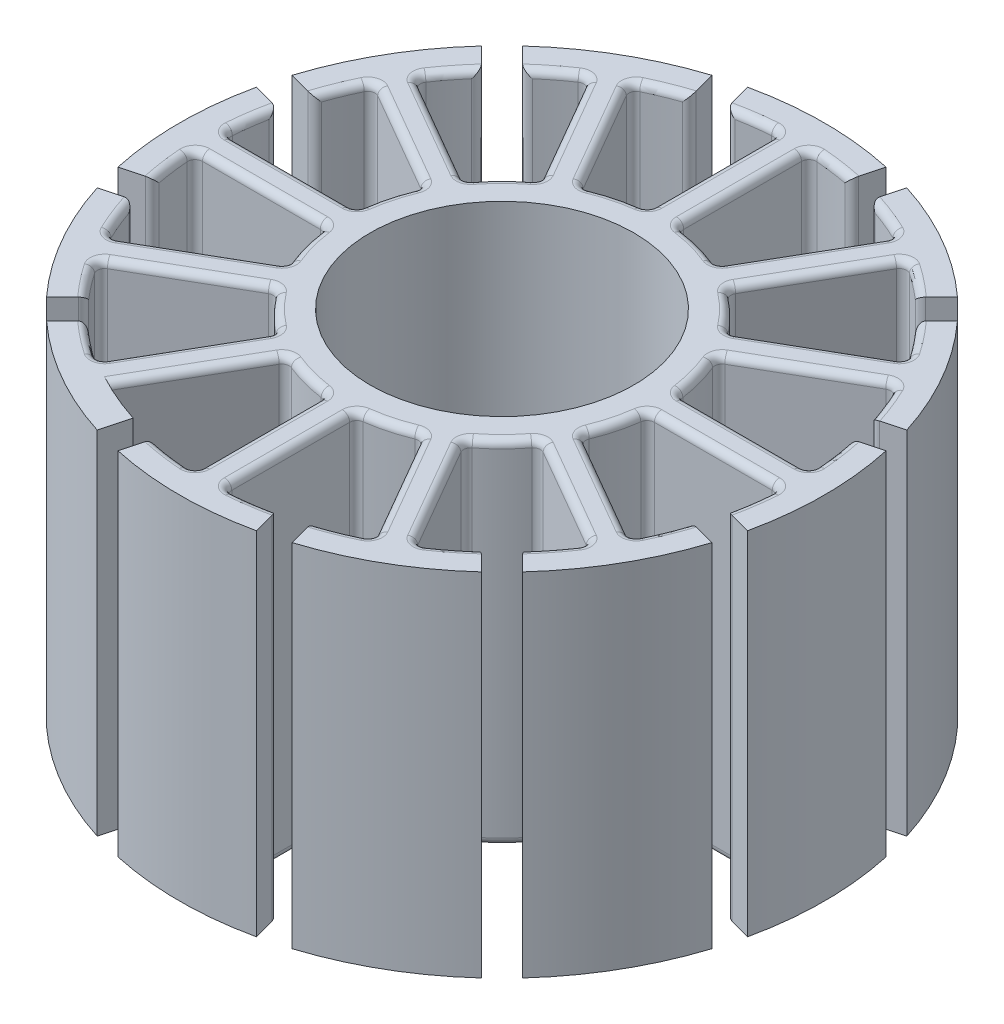
from build123d import *

# Parameters (mm, degrees)
SKETCH1_R           = 5.5
SKETCH1_R_2         = 4.5
BOSS_EXTRUDE1_DEPTH = 12
FILLET2_R           = 0.25


with BuildPart() as part:
    # Sketch1 → Boss-Extrude1 (new body)
    with BuildSketch(Plane(origin=(0, 0, 0), x_dir=(1, 0, 0), z_dir=(0, 1, 0))):
        Circle(SKETCH1_R)
        Circle(SKETCH1_R_2, mode=Mode.SUBTRACT)
        with BuildLine():
            ThreePointArc((-4.49341649, -3.171625489), (-4.763139721, -2.75), (-4.99341649, -2.305600086))
            Line((-4.99341649, -2.305600086), (-8.899421946, -4.560733387))
            ThreePointArc((-8.899421946, -4.560733387), (-8.660254038, -5), (-8.399421946, -5.426758791))
            Line((-8.399421946, -5.426758791), (-4.49341649, -3.171625489))
        make_face()
        with BuildLine():
            ThreePointArc((-5.477225575, -0.5), (-5.5, 0), (-5.477225575, 0.5))
            Line((-5.477225575, 0.5), (-9.987492178, 0.5))
            ThreePointArc((-9.987492178, 0.5), (-10, 0), (-9.987492178, -0.5))
            Line((-9.987492178, -0.5), (-5.477225575, -0.5))
        make_face()
        with BuildLine():
            ThreePointArc((-4.99341649, 2.305600086), (-4.763139721, 2.75), (-4.49341649, 3.171625489))
            Line((-4.49341649, 3.171625489), (-8.399421946, 5.426758791))
            ThreePointArc((-8.399421946, 5.426758791), (-8.660254038, 5), (-8.899421946, 4.560733387))
            Line((-8.899421946, 4.560733387), (-4.99341649, 2.305600086))
        make_face()
        with BuildLine():
            ThreePointArc((-3.171625489, 4.49341649), (-2.75, 4.763139721), (-2.305600086, 4.99341649))
            Line((-2.305600086, 4.99341649), (-4.560733387, 8.899421946))
            ThreePointArc((-4.560733387, 8.899421946), (-5, 8.660254038), (-5.426758791, 8.399421946))
            Line((-5.426758791, 8.399421946), (-3.171625489, 4.49341649))
        make_face()
        with BuildLine():
            ThreePointArc((0.5, 9.987492178), (0, 10), (-0.5, 9.987492178))
            Line((-0.5, 9.987492178), (-0.5, 5.477225575))
            ThreePointArc((-0.5, 5.477225575), (0, 5.5), (0.5, 5.477225575))
            Line((0.5, 5.477225575), (0.5, 9.987492178))
        make_face()
        with BuildLine():
            Line((4.560733387, 8.899421946), (2.305600086, 4.99341649))
            ThreePointArc((2.305600086, 4.99341649), (2.75, 4.763139721), (3.171625489, 4.49341649))
            Line((3.171625489, 4.49341649), (5.426758791, 8.399421946))
            ThreePointArc((5.426758791, 8.399421946), (5, 8.660254038), (4.560733387, 8.899421946))
        make_face()
        with BuildLine():
            Line((8.399421946, 5.426758791), (4.49341649, 3.171625489))
            ThreePointArc((4.49341649, 3.171625489), (4.763139721, 2.75), (4.99341649, 2.305600086))
            Line((4.99341649, 2.305600086), (8.899421946, 4.560733387))
            ThreePointArc((8.899421946, 4.560733387), (8.660254038, 5), (8.399421946, 5.426758791))
        make_face()
        with BuildLine():
            Line((9.987492178, 0.5), (5.477225575, 0.5))
            ThreePointArc((5.477225575, 0.5), (5.494303444, 0.250259203), (5.5, 0))
            ThreePointArc((5.5, 0), (5.494303444, -0.250259203), (5.477225575, -0.5))
            Line((5.477225575, -0.5), (9.987492178, -0.5))
            ThreePointArc((9.987492178, -0.5), (9.996872555, -0.250078211), (10, 0))
            ThreePointArc((10, 0), (9.996872555, 0.250078211), (9.987492178, 0.5))
        make_face()
        with BuildLine():
            Line((8.899421946, -4.560733387), (4.99341649, -2.305600086))
            ThreePointArc((4.99341649, -2.305600086), (4.763139721, -2.75), (4.49341649, -3.171625489))
            Line((4.49341649, -3.171625489), (8.399421946, -5.426758791))
            ThreePointArc((8.399421946, -5.426758791), (8.660254038, -5), (8.899421946, -4.560733387))
        make_face()
        with BuildLine():
            Line((5.426758791, -8.399421946), (3.171625489, -4.49341649))
            ThreePointArc((3.171625489, -4.49341649), (2.75, -4.763139721), (2.305600086, -4.99341649))
            Line((2.305600086, -4.99341649), (4.560733387, -8.899421946))
            ThreePointArc((4.560733387, -8.899421946), (5, -8.660254038), (5.426758791, -8.399421946))
        make_face()
        with BuildLine():
            ThreePointArc((0.5, -5.477225575), (0, -5.5), (-0.5, -5.477225575))
            Line((-0.5, -5.477225575), (-0.5, -9.987492178))
            ThreePointArc((-0.5, -9.987492178), (0, -10), (0.5, -9.987492178))
            Line((0.5, -9.987492178), (0.5, -5.477225575))
        make_face()
        with BuildLine():
            ThreePointArc((-2.305600086, -4.99341649), (-2.75, -4.763139721), (-3.171625489, -4.49341649))
            Line((-3.171625489, -4.49341649), (-5.426758791, -8.399421946))
            ThreePointArc((-5.426758791, -8.399421946), (-5, -8.660254038), (-4.560733387, -8.899421946))
            Line((-4.560733387, -8.899421946), (-2.305600086, -4.99341649))
        make_face()
        with BuildLine():
            ThreePointArc((-4.560733387, -8.899421946), (-5, -8.660254038), (-5.426758791, -8.399421946))
            ThreePointArc((-5.426758791, -8.399421946), (-6.08761429, -7.933533403), (-6.708670055, -7.415776837))
            Line((-6.708670055, -7.415776837), (-7.416581743, -8.123688525))
            ThreePointArc((-7.416581743, -8.123688525), (-5.5, -9.526279442), (-3.327029763, -10.484792461))
            Line((-3.327029763, -10.484792461), (-3.067916102, -9.517767112))
            ThreePointArc((-3.067916102, -9.517767112), (-3.826834324, -9.238795325), (-4.560733387, -8.899421946))
        make_face()
        with BuildLine():
            ThreePointArc((-8.399421946, -5.426758791), (-8.660254038, -5), (-8.899421946, -4.560733387))
            ThreePointArc((-8.899421946, -4.560733387), (-9.238795325, -3.826834324), (-9.517767112, -3.067916102))
            Line((-9.517767112, -3.067916102), (-10.484792461, -3.327029763))
            ThreePointArc((-10.484792461, -3.327029763), (-9.526279442, -5.5), (-8.123688525, -7.416581743))
            Line((-8.123688525, -7.416581743), (-7.415776837, -6.708670055))
            ThreePointArc((-7.415776837, -6.708670055), (-7.933533403, -6.08761429), (-8.399421946, -5.426758791))
        make_face()
        with BuildLine():
            ThreePointArc((-9.987492178, -0.5), (-10, 0), (-9.987492178, 0.5))
            ThreePointArc((-9.987492178, 0.5), (-9.914448614, 1.305261922), (-9.776586157, 2.101990275))
            Line((-9.776586157, 2.101990275), (-10.743611506, 2.361103937))
            ThreePointArc((-10.743611506, 2.361103937), (-11, 0), (-10.743611506, -2.361103937))
            Line((-10.743611506, -2.361103937), (-9.776586157, -2.101990275))
            ThreePointArc((-9.776586157, -2.101990275), (-9.914448614, -1.305261922), (-9.987492178, -0.5))
        make_face()
        with BuildLine():
            ThreePointArc((-4.560733387, 8.899421946), (-3.826834324, 9.238795325), (-3.067916102, 9.517767112))
            Line((-3.067916102, 9.517767112), (-3.327029763, 10.484792461))
            ThreePointArc((-3.327029763, 10.484792461), (-5.5, 9.526279442), (-7.416581743, 8.123688525))
            Line((-7.416581743, 8.123688525), (-6.708670055, 7.415776837))
            ThreePointArc((-6.708670055, 7.415776837), (-6.08761429, 7.933533403), (-5.426758791, 8.399421946))
            ThreePointArc((-5.426758791, 8.399421946), (-5, 8.660254038), (-4.560733387, 8.899421946))
        make_face()
        with BuildLine():
            ThreePointArc((-8.899421946, 4.560733387), (-8.660254038, 5), (-8.399421946, 5.426758791))
            ThreePointArc((-8.399421946, 5.426758791), (-7.933533403, 6.08761429), (-7.415776837, 6.708670055))
            Line((-7.415776837, 6.708670055), (-8.123688525, 7.416581743))
            ThreePointArc((-8.123688525, 7.416581743), (-9.526279442, 5.5), (-10.484792461, 3.327029763))
            Line((-10.484792461, 3.327029763), (-9.517767112, 3.067916102))
            ThreePointArc((-9.517767112, 3.067916102), (-9.238795325, 3.826834324), (-8.899421946, 4.560733387))
        make_face()
        with BuildLine():
            ThreePointArc((-2.101990275, 9.776586157), (-1.305261922, 9.914448614), (-0.5, 9.987492178))
            ThreePointArc((-0.5, 9.987492178), (0, 10), (0.5, 9.987492178))
            ThreePointArc((0.5, 9.987492178), (1.305261922, 9.914448614), (2.101990275, 9.776586157))
            Line((2.101990275, 9.776586157), (2.361103937, 10.743611506))
            ThreePointArc((2.361103937, 10.743611506), (0, 11), (-2.361103937, 10.743611506))
            Line((-2.361103937, 10.743611506), (-2.101990275, 9.776586157))
        make_face()
        with BuildLine():
            Line((3.327029763, 10.484792461), (3.067916102, 9.517767112))
            ThreePointArc((3.067916102, 9.517767112), (3.826834324, 9.238795325), (4.560733387, 8.899421946))
            ThreePointArc((4.560733387, 8.899421946), (5, 8.660254038), (5.426758791, 8.399421946))
            ThreePointArc((5.426758791, 8.399421946), (6.08761429, 7.933533403), (6.708670055, 7.415776837))
            Line((6.708670055, 7.415776837), (7.416581743, 8.123688525))
            ThreePointArc((7.416581743, 8.123688525), (5.5, 9.526279442), (3.327029763, 10.484792461))
        make_face()
        with BuildLine():
            ThreePointArc((7.415776837, 6.708670055), (7.933533403, 6.08761429), (8.399421946, 5.426758791))
            ThreePointArc((8.399421946, 5.426758791), (8.660254038, 5), (8.899421946, 4.560733387))
            ThreePointArc((8.899421946, 4.560733387), (9.238795325, 3.826834324), (9.517767112, 3.067916102))
            Line((9.517767112, 3.067916102), (10.484792461, 3.327029763))
            ThreePointArc((10.484792461, 3.327029763), (9.526279442, 5.5), (8.123688525, 7.416581743))
            Line((8.123688525, 7.416581743), (7.415776837, 6.708670055))
        make_face()
        with BuildLine():
            ThreePointArc((9.776586157, 2.101990275), (9.914448614, 1.305261922), (9.987492178, 0.5))
            ThreePointArc((9.987492178, 0.5), (9.996872555, 0.250078211), (10, 0))
            ThreePointArc((10, 0), (9.996872555, -0.250078211), (9.987492178, -0.5))
            ThreePointArc((9.987492178, -0.5), (9.914448614, -1.305261922), (9.776586157, -2.101990275))
            Line((9.776586157, -2.101990275), (10.743611506, -2.361103937))
            ThreePointArc((10.743611506, -2.361103937), (10.935715033, -1.187491775), (11, 0))
            ThreePointArc((11, 0), (10.935715033, 1.187491775), (10.743611506, 2.361103937))
            Line((10.743611506, 2.361103937), (9.776586157, 2.101990275))
        make_face()
        with BuildLine():
            ThreePointArc((9.517767112, -3.067916102), (9.238795325, -3.826834324), (8.899421946, -4.560733387))
            ThreePointArc((8.899421946, -4.560733387), (8.660254038, -5), (8.399421946, -5.426758791))
            ThreePointArc((8.399421946, -5.426758791), (7.933533403, -6.08761429), (7.415776837, -6.708670055))
            Line((7.415776837, -6.708670055), (8.123688525, -7.416581743))
            ThreePointArc((8.123688525, -7.416581743), (9.526279442, -5.5), (10.484792461, -3.327029763))
            Line((10.484792461, -3.327029763), (9.517767112, -3.067916102))
        make_face()
        with BuildLine():
            ThreePointArc((6.708670055, -7.415776837), (6.08761429, -7.933533403), (5.426758791, -8.399421946))
            ThreePointArc((5.426758791, -8.399421946), (5, -8.660254038), (4.560733387, -8.899421946))
            ThreePointArc((4.560733387, -8.899421946), (3.826834324, -9.238795325), (3.067916102, -9.517767112))
            Line((3.067916102, -9.517767112), (3.327029763, -10.484792461))
            ThreePointArc((3.327029763, -10.484792461), (5.5, -9.526279442), (7.416581743, -8.123688525))
            Line((7.416581743, -8.123688525), (6.708670055, -7.415776837))
        make_face()
        with BuildLine():
            ThreePointArc((0.5, -9.987492178), (0, -10), (-0.5, -9.987492178))
            ThreePointArc((-0.5, -9.987492178), (-1.305261922, -9.914448614), (-2.101990275, -9.776586157))
            Line((-2.101990275, -9.776586157), (-2.361103937, -10.743611506))
            ThreePointArc((-2.361103937, -10.743611506), (0, -11), (2.361103937, -10.743611506))
            Line((2.361103937, -10.743611506), (2.101990275, -9.776586157))
            ThreePointArc((2.101990275, -9.776586157), (1.305261922, -9.914448614), (0.5, -9.987492178))
        make_face()
    extrude(amount=BOSS_EXTRUDE1_DEPTH)

    # Fillet2
    fillet2_edges = [part.edges().sort_by_distance(p)[0] for p in [
        (0.5, 0, 7.732358876),
        (0.5, 12, 7.732358876),
        (3.433166736, 0, 6.946419218),
        (3.433166736, 12, 6.946419218),
        (-3.433166736, 0, 6.946419218),
        (-3.433166736, 12, 6.946419218),
        (-0.5, 0, 7.732358876),
        (-0.5, 12, 7.732358876),
        (-6.446419218, 0, 4.29919214),
        (-6.446419218, 12, 4.29919214),
        (-4.29919214, 0, 6.446419218),
        (-4.29919214, 12, 6.446419218),
        (-7.732358876, 0, 0.5),
        (-7.732358876, 12, 0.5),
        (-6.946419218, 0, 3.433166736),
        (-6.946419218, 12, 3.433166736),
        (-6.946419218, 0, -3.433166736),
        (-6.946419218, 12, -3.433166736),
        (-7.732358876, 0, -0.5),
        (-7.732358876, 12, -0.5),
        (-4.29919214, 0, -6.446419218),
        (-4.29919214, 12, -6.446419218),
        (-6.446419218, 0, -4.29919214),
        (-6.446419218, 12, -4.29919214),
        (-0.5, 0, -7.732358876),
        (-0.5, 12, -7.732358876),
        (-3.433166736, 0, -6.946419218),
        (-3.433166736, 12, -6.946419218),
        (3.433166736, 0, -6.946419218),
        (3.433166736, 12, -6.946419218),
        (0.5, 0, -7.732358876),
        (0.5, 12, -7.732358876),
        (6.446419218, 0, -4.29919214),
        (6.446419218, 12, -4.29919214),
        (4.29919214, 0, -6.446419218),
        (4.29919214, 12, -6.446419218),
        (7.732358876, 0, -0.5),
        (7.732358876, 12, -0.5),
        (6.946419218, 0, -3.433166736),
        (6.946419218, 12, -3.433166736),
        (6.946419218, 0, 3.433166736),
        (6.946419218, 12, 3.433166736),
        (7.732358876, 0, 0.5),
        (7.732358876, 12, 0.5),
        (4.29919214, 0, 6.446419218),
        (4.29919214, 12, 6.446419218),
        (6.446419218, 0, 4.29919214),
        (6.446419218, 12, 4.29919214),
        (0.5, 6, 5.477225575),
        (1.423504748, 12, 5.312592045),
        (1.423504748, 0, 5.312592045),
        (2.305600086, 6, 4.99341649),
        (-2.305600086, 6, 4.99341649),
        (-1.423504748, 12, 5.312592045),
        (-1.423504748, 0, 5.312592045),
        (-0.5, 6, 5.477225575),
        (-4.49341649, 6, 3.171625489),
        (-3.889087297, 12, 3.889087297),
        (-3.889087297, 0, 3.889087297),
        (-3.171625489, 6, 4.49341649),
        (-5.477225575, 6, 0.5),
        (-5.312592045, 12, 1.423504748),
        (-5.312592045, 0, 1.423504748),
        (-4.99341649, 6, 2.305600086),
        (-4.99341649, 6, -2.305600086),
        (-5.312592045, 12, -1.423504748),
        (-5.312592045, 0, -1.423504748),
        (-5.477225575, 6, -0.5),
        (-3.171625489, 6, -4.49341649),
        (-3.889087297, 12, -3.889087297),
        (-3.889087297, 0, -3.889087297),
        (-4.49341649, 6, -3.171625489),
        (-0.5, 6, -5.477225575),
        (-1.423504748, 12, -5.312592045),
        (-1.423504748, 0, -5.312592045),
        (-2.305600086, 6, -4.99341649),
        (2.305600086, 6, -4.99341649),
        (1.423504748, 12, -5.312592045),
        (1.423504748, 0, -5.312592045),
        (0.5, 6, -5.477225575),
        (4.49341649, 6, -3.171625489),
        (3.889087297, 12, -3.889087297),
        (3.889087297, 0, -3.889087297),
        (3.171625489, 6, -4.49341649),
        (5.477225575, 6, -0.5),
        (5.312592045, 12, -1.423504748),
        (5.312592045, 0, -1.423504748),
        (4.99341649, 6, -2.305600086),
        (4.99341649, 6, 2.305600086),
        (5.312592045, 12, 1.423504748),
        (5.312592045, 0, 1.423504748),
        (5.477225575, 6, 0.5),
        (3.171625489, 6, 4.49341649),
        (3.889087297, 12, 3.889087297),
        (3.889087297, 0, 3.889087297),
        (4.49341649, 6, 3.171625489),
        (8.899421946, 6, -4.560733387),
        (9.238795325, 12, -3.826834324),
        (9.238795325, 0, -3.826834324),
        (9.517767112, 6, -3.067916102),
        (7.415776837, 6, -6.708670055),
        (7.933533403, 12, -6.08761429),
        (7.933533403, 0, -6.08761429),
        (8.399421946, 6, -5.426758791),
        (5.426758791, 6, -8.399421946),
        (6.08761429, 12, -7.933533403),
        (6.08761429, 0, -7.933533403),
        (6.708670055, 6, -7.415776837),
        (3.067916102, 6, -9.517767112),
        (3.826834324, 12, -9.238795325),
        (3.826834324, 0, -9.238795325),
        (4.560733387, 6, -8.899421946),
        (0.5, 6, -9.987492178),
        (1.305261922, 12, -9.914448614),
        (1.305261922, 0, -9.914448614),
        (2.101990275, 6, -9.776586157),
        (-2.101990275, 6, -9.776586157),
        (-1.305261922, 12, -9.914448614),
        (-1.305261922, 0, -9.914448614),
        (-0.5, 6, -9.987492178),
        (-4.560733387, 6, -8.899421946),
        (-3.826834324, 12, -9.238795325),
        (-3.826834324, 0, -9.238795325),
        (-3.067916102, 6, -9.517767112),
        (-6.708670055, 6, -7.415776837),
        (-6.08761429, 12, -7.933533403),
        (-6.08761429, 0, -7.933533403),
        (-5.426758791, 6, -8.399421946),
        (-8.399421946, 6, -5.426758791),
        (-7.933533403, 12, -6.08761429),
        (-7.933533403, 0, -6.08761429),
        (-7.415776837, 6, -6.708670055),
        (-9.517767112, 6, -3.067916102),
        (-9.238795325, 12, -3.826834324),
        (-9.238795325, 0, -3.826834324),
        (-8.899421946, 6, -4.560733387),
        (-9.987492178, 6, -0.5),
        (-9.914448614, 12, -1.305261922),
        (-9.914448614, 0, -1.305261922),
        (-9.776586157, 6, -2.101990275),
        (-9.776586157, 6, 2.101990275),
        (-9.914448614, 12, 1.305261922),
        (-9.914448614, 0, 1.305261922),
        (-9.987492178, 6, 0.5),
        (-8.899421946, 6, 4.560733387),
        (-9.238795325, 12, 3.826834324),
        (-9.238795325, 0, 3.826834324),
        (-9.517767112, 6, 3.067916102),
        (-7.415776837, 6, 6.708670055),
        (-7.933533403, 12, 6.08761429),
        (-7.933533403, 0, 6.08761429),
        (-8.399421946, 6, 5.426758791),
        (-5.426758791, 6, 8.399421946),
        (-6.08761429, 12, 7.933533403),
        (-6.08761429, 0, 7.933533403),
        (-6.708670055, 6, 7.415776837),
        (-0.5, 6, 9.987492178),
        (-1.305261922, 12, 9.914448614),
        (-1.305261922, 0, 9.914448614),
        (-2.101990275, 6, 9.776586157),
        (2.101990275, 6, 9.776586157),
        (1.305261922, 12, 9.914448614),
        (1.305261922, 0, 9.914448614),
        (0.5, 6, 9.987492178),
        (9.776586157, 6, -2.101990275),
        (9.914448614, 12, -1.305261922),
        (9.914448614, 0, -1.305261922),
        (9.987492178, 6, -0.5),
        (9.987492178, 6, 0.5),
        (9.914448614, 12, 1.305261922),
        (9.914448614, 0, 1.305261922),
        (9.776586157, 6, 2.101990275),
        (9.517767112, 6, 3.067916102),
        (9.238795325, 12, 3.826834324),
        (9.238795325, 0, 3.826834324),
        (8.899421946, 6, 4.560733387),
        (8.399421946, 6, 5.426758791),
        (7.933533403, 12, 6.08761429),
        (7.933533403, 0, 6.08761429),
        (7.415776837, 6, 6.708670055),
        (6.708670055, 6, 7.415776837),
        (6.08761429, 12, 7.933533403),
        (6.08761429, 0, 7.933533403),
        (5.426758791, 6, 8.399421946),
        (4.560733387, 6, 8.899421946),
        (3.826834324, 12, 9.238795325),
        (3.826834324, 0, 9.238795325),
        (3.067916102, 6, 9.517767112),
    ]]
    fillet(fillet2_edges, radius=FILLET2_R)


solid = part.part
